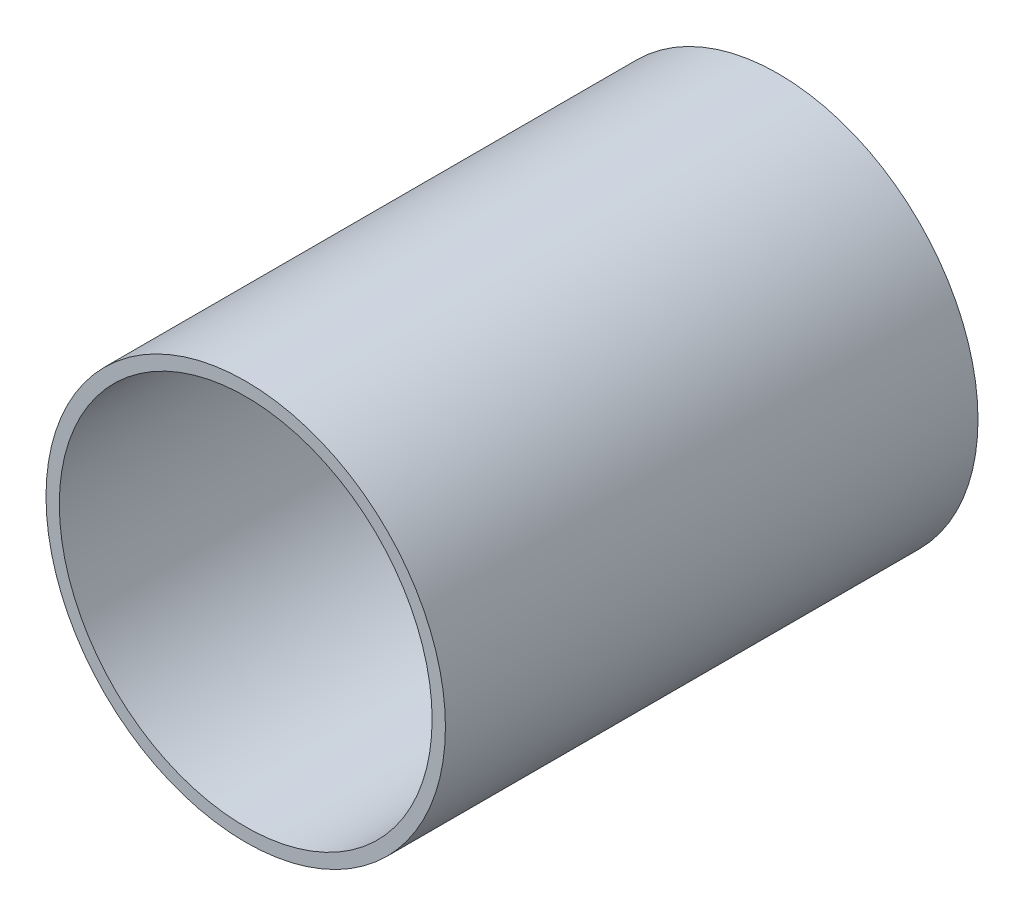
from build123d import *

# Parameters (mm, degrees)
ESQUISSE1_R        = 75
ESQUISSE1_R_2      = 70
BOSS_EXTRU_1_DEPTH = 200
ESQUISSE2_R        = 70
BOSS_EXTRU_2_DEPTH = 5


with BuildPart() as part:
    # Esquisse1 → Boss.-Extru.1 (new body)
    with BuildSketch(Plane.XY):
        Circle(ESQUISSE1_R)
        Circle(ESQUISSE1_R_2, mode=Mode.SUBTRACT)
    extrude(amount=BOSS_EXTRU_1_DEPTH)

    # Esquisse2 → Boss.-Extru.2 (add)
    with BuildSketch(Plane(origin=(0, 0, 0), x_dir=(-1, 0, 0), z_dir=(0, 0, -1))):
        Circle(ESQUISSE2_R)
    extrude(amount=-BOSS_EXTRU_2_DEPTH)


solid = part.part
